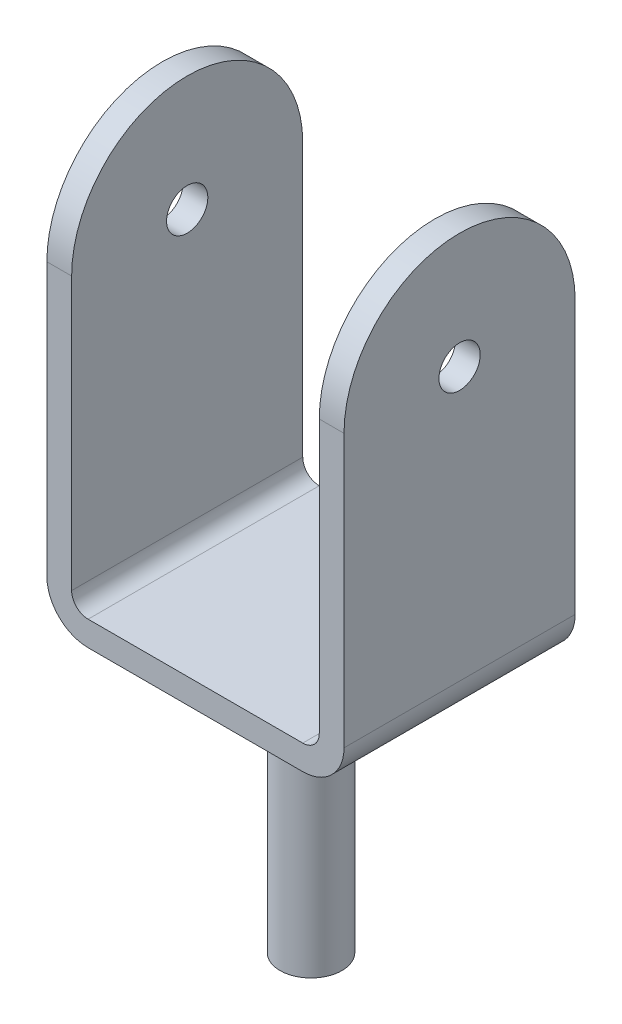
from build123d import *

# Parameters (mm, degrees)
SKETCH1_R           = 37.5
BOSS_EXTRUDE1_DEPTH = 325
SKETCH2_W           = 360
SKETCH2_H           = 280
BOSS_EXTRUDE2_DEPTH = 520
SKETCH3_W           = 300
SKETCH3_H           = 490
CUT_EXTRUDE1_DEPTH  = 367
FILLET1_R           = 20
FILLET3_R           = 50
SKETCH4_R           = 25
CUT_EXTRUDE2_DEPTH  = 367


with BuildPart() as part:
    # Sketch1 → Boss-Extrude1 (new body)
    with BuildSketch(Plane(origin=(0, 0, 0), x_dir=(1, 0, 0), z_dir=(0, 1, 0))):
        Circle(SKETCH1_R)
    extrude(amount=BOSS_EXTRUDE1_DEPTH)

    # Sketch2 → Boss-Extrude2 (add)
    with BuildSketch(Plane(origin=(0, 325, 0), x_dir=(1, 0, 0), z_dir=(0, 1, 0))):
        Rectangle(SKETCH2_W, SKETCH2_H)
    extrude(amount=BOSS_EXTRUDE2_DEPTH)

    # Sketch3 → Cut-Extrude1 (cut)
    with BuildSketch(Plane.XY.offset(140)):
        with Locations((0, 600)):
            Rectangle(SKETCH3_W, SKETCH3_H)
    extrude(amount=-CUT_EXTRUDE1_DEPTH, mode=Mode.SUBTRACT)

    # Fillet1
    fillet1_edges = [part.edges().sort_by_distance(p)[0] for p in [
        (150, 355, 0),
        (-150, 355, 0),
    ]]
    fillet(fillet1_edges, radius=FILLET1_R)

    # Fillet3
    fillet3_edges = [part.edges().sort_by_distance(p)[0] for p in [
        (180, 325, 0),
        (-180, 325, 0),
    ]]
    fillet(fillet3_edges, radius=FILLET3_R)

    # Sketch4 → Cut-Extrude2 (cut)
    with BuildSketch(Plane(origin=(180, 0, 0), x_dir=(0, 0, -1), z_dir=(1, 0, 0))):
        with BuildLine():
            Line((-140, 845), (-140, 705))
            ThreePointArc((-140, 705), (-98.994949067, 803.994949665), (8.46e-07, 845))
            Line((8.46e-07, 845), (-140, 845))
        make_face()
        with BuildLine():
            ThreePointArc((8.46e-07, 845), (98.994949665, 803.994949067), (140, 705))
            Line((140, 705), (140, 845))
            Line((140, 845), (8.46e-07, 845))
        make_face()
        with Locations((0, 705)):
            Circle(SKETCH4_R)
    extrude(amount=-CUT_EXTRUDE2_DEPTH, mode=Mode.SUBTRACT)


solid = part.part
